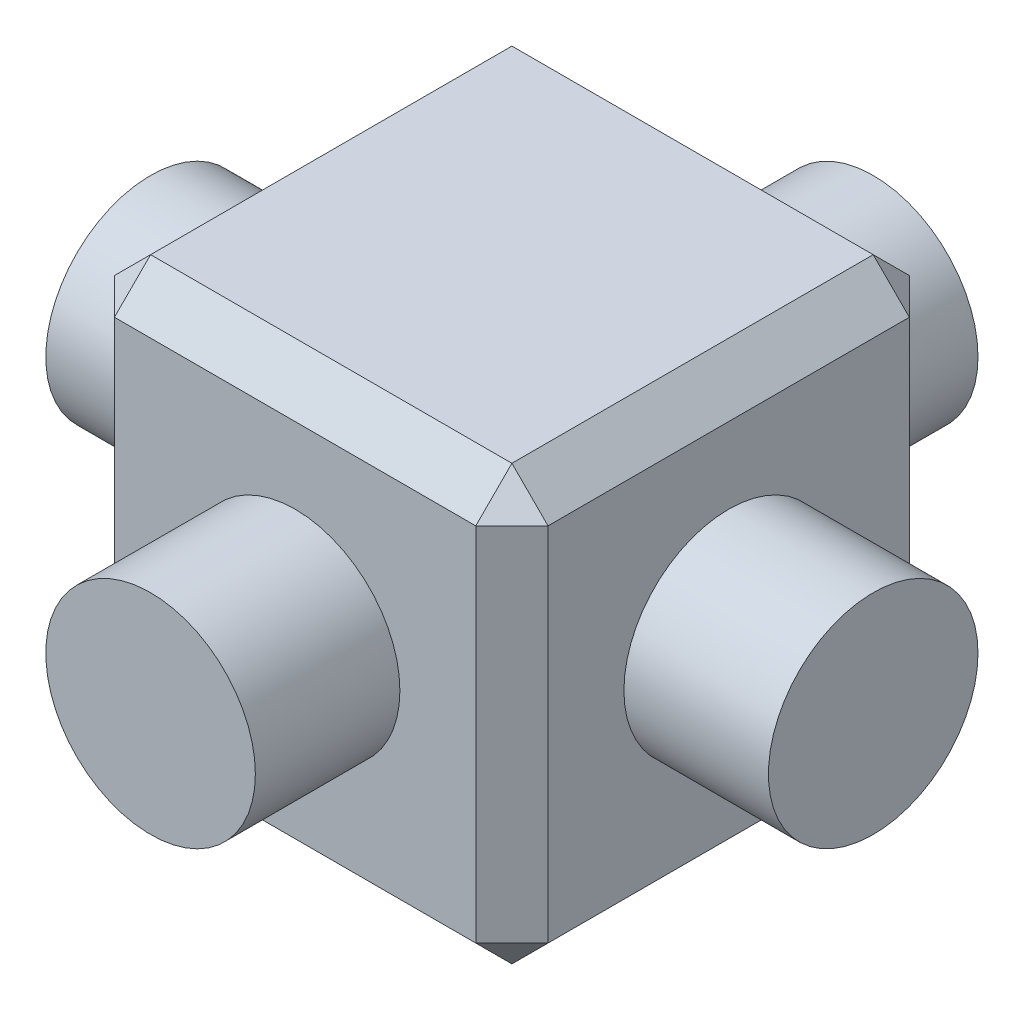
from build123d import *

# Parameters (mm, degrees)
SKETCH1_W                = 6
SKETCH1_H                = 6
BOSS_EXTRUDE1_DEPTH      = 6
SKETCH2_R                = 1.45
BOSS_EXTRUDE2_DEPTH      = 2
BOSS_EXTRUDE2_DEPTH_BACK = 8
SKETCH3_R                = 1.45
BOSS_EXTRUDE3_DEPTH      = 2
BOSS_EXTRUDE3_DEPTH_BACK = 8
CHAMFER1_SIZE            = 0.5


with BuildPart() as part:
    # Sketch1 → Boss-Extrude1 (new body)
    with BuildSketch(Plane(origin=(0, 0, 0), x_dir=(1, 0, 0), z_dir=(0, 1, 0))):
        Rectangle(SKETCH1_W, SKETCH1_H)
    extrude(amount=BOSS_EXTRUDE1_DEPTH)

    # Sketch2 → Boss-Extrude2 (add, two sides)
    with BuildSketch(Plane(origin=(3, 0, 0), x_dir=(0, 0, -1), z_dir=(1, 0, 0))) as boss_extrude2_sk:
        with Locations((0, 3)):
            Circle(SKETCH2_R)
    extrude(amount=BOSS_EXTRUDE2_DEPTH)
    extrude(boss_extrude2_sk.sketch, amount=-BOSS_EXTRUDE2_DEPTH_BACK)

    # Sketch3 → Boss-Extrude3 (add, two sides)
    with BuildSketch(Plane.XY.offset(3)) as boss_extrude3_sk:
        with Locations((0, 3)):
            Circle(SKETCH3_R)
    extrude(amount=BOSS_EXTRUDE3_DEPTH)
    extrude(boss_extrude3_sk.sketch, amount=-BOSS_EXTRUDE3_DEPTH_BACK)

    # Chamfer1
    chamfer1_edges = [part.edges().sort_by_distance(p)[0] for p in [
        (-3, 6, 0),
        (0, 6, 3),
        (3, 6, 0),
        (0, 0, 3),
        (-3, 0, 0),
        (0, 0, -3),
        (3, 0, 0),
        (3, 3, 3),
        (-3, 3, 3),
        (-3, 3, -3),
        (3, 3, -3),
        (0, 6, -3),
    ]]
    chamfer(chamfer1_edges, length=CHAMFER1_SIZE)


solid = part.part
